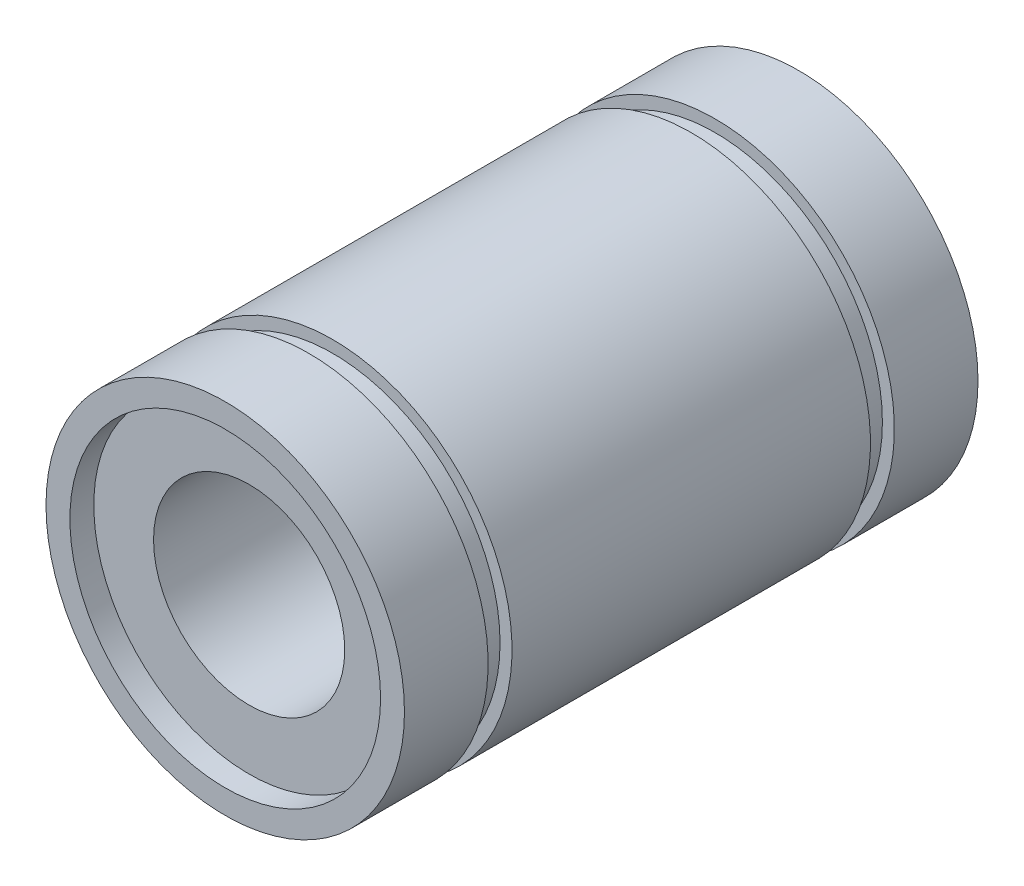
from build123d import *

# Parameters (mm, degrees)
SKETCH1_R           = 7.5
SKETCH1_R_2         = 6.5
BOSS_EXTRUDE1_DEPTH = 12
SKETCH2_R           = 6.5
SKETCH2_R_2         = 4
BOSS_EXTRUDE2_DEPTH = 11
SKETCH3_W           = 0.5
SKETCH3_H           = 1


with BuildPart() as part:
    # Sketch1 → Boss-Extrude1 (new body, symmetric)
    with BuildSketch(Plane.XY):
        Circle(SKETCH1_R)
        Circle(SKETCH1_R_2, mode=Mode.SUBTRACT)
    extrude(amount=BOSS_EXTRUDE1_DEPTH, both=True)

    # Sketch3 → Cut-Revolve1 (revolve, cut)
    with BuildSketch(Plane(origin=(0, 0, 0), x_dir=(1, 0, 0), z_dir=(0, 1, 0))):
        with Locations((7.25, 8)):
            Rectangle(SKETCH3_W, SKETCH3_H)
        with Locations((7.25, -8)):
            Rectangle(SKETCH3_W, SKETCH3_H)
    revolve(axis=Axis((0, 0, -12), (0, 0, 1)), mode=Mode.SUBTRACT)


with BuildPart() as body_2:
    # Sketch2 → Boss-Extrude2 (new body, symmetric)
    with BuildSketch(Plane.XY):
        Circle(SKETCH2_R)
        Circle(SKETCH2_R_2, mode=Mode.SUBTRACT)
    extrude(amount=BOSS_EXTRUDE2_DEPTH, both=True)


solid = Compound([part.part, body_2.part])
